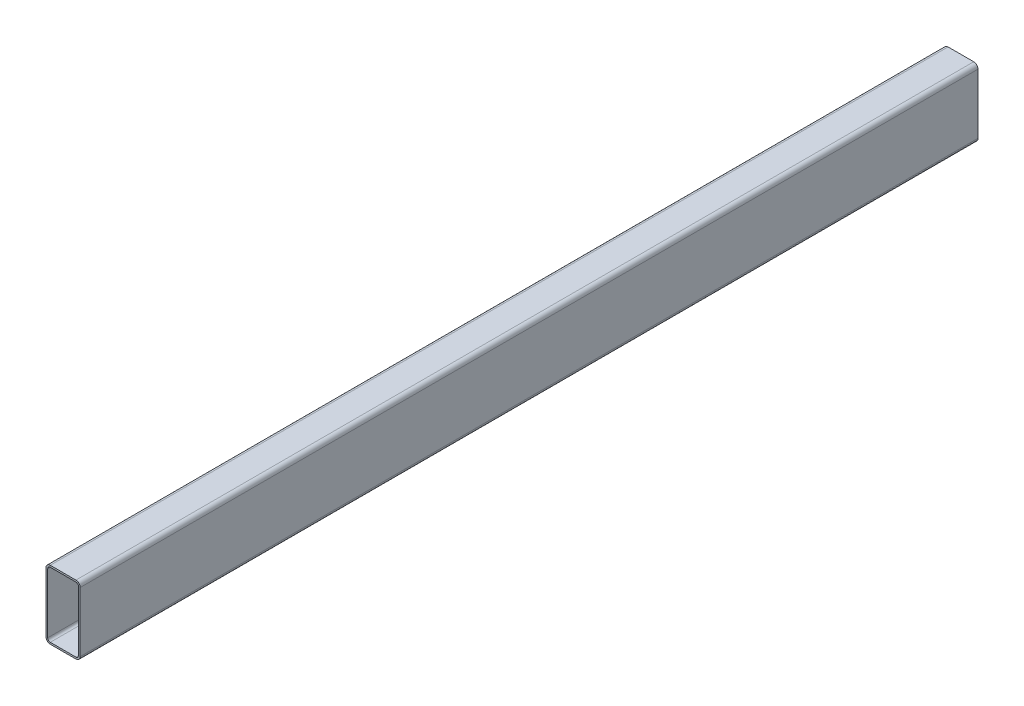
from build123d import *

# Parameters (mm, degrees)
BOSS_EXTRUDE1_DEPTH = 1050


with BuildPart() as part:
    # Sketch1 → Boss-Extrude1 (new body)
    with BuildSketch(Plane.XY):
        with BuildLine():
            Line((-15, -40), (15, -40))
            ThreePointArc((15, -40), (18.535533906, -38.535533906), (20, -35))
            Line((20, -35), (20, 35))
            ThreePointArc((20, 35), (18.535533906, 38.535533906), (15, 40))
            Line((15, 40), (-15, 40))
            ThreePointArc((-15, 40), (-18.535533906, 38.535533906), (-20, 35))
            Line((-20, 35), (-20, -35))
            ThreePointArc((-20, -35), (-18.535533906, -38.535533906), (-15, -40))
        make_face()
        with BuildLine():
            Line((-18, -35), (-18, 35))
            ThreePointArc((-18, 35), (-17.121320344, 37.121320344), (-15, 38))
            Line((-15, 38), (15, 38))
            ThreePointArc((15, 38), (17.121320344, 37.121320344), (18, 35))
            Line((18, 35), (18, -35))
            ThreePointArc((18, -35), (17.121320344, -37.121320344), (15, -38))
            Line((15, -38), (-15, -38))
            ThreePointArc((-15, -38), (-17.121320344, -37.121320344), (-18, -35))
        make_face(mode=Mode.SUBTRACT)
    extrude(amount=BOSS_EXTRUDE1_DEPTH)


solid = part.part
